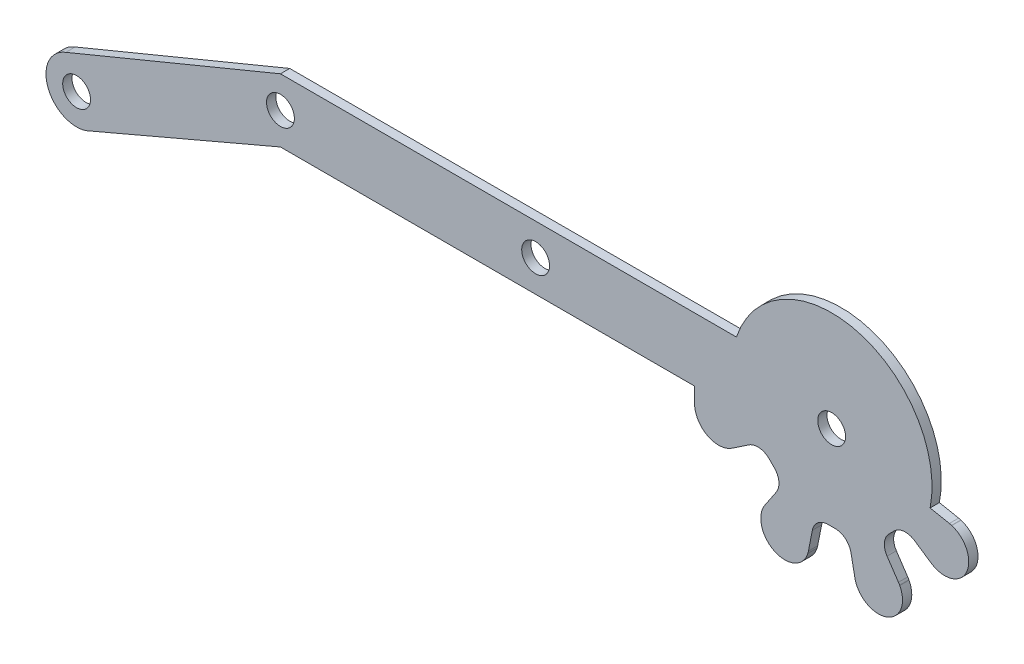
from build123d import *

# Parameters (mm, degrees)
MODEL_R                 = 1.5
SALIENTE_EXTRUIR1_DEPTH = 1


with BuildPart() as part:
    # Model → Saliente-Extruir1 (new body)
    with BuildSketch(Plane.XY):
        with BuildLine():
            Line((6.261217919, 18.769360839), (-14.739513879, 9.794996238))
            ThreePointArc((-14.739513879, 9.794996238), (-18.828558612, 11.883464999), (-16.872209477, 16.037341099))
            Line((-16.872209477, 16.037341099), (6.261217919, 25.600360839))
            Line((6.261217919, 25.600360839), (33.761217919, 25.600360839))
            Line((33.761217919, 25.600360839), (55.398917602, 25.600360839))
            ThreePointArc((55.398917602, 25.600360839), (68.422679159, 32.642144419), (76.271846628, 20.088433767))
            Line((76.271846628, 20.088433767), (78.346726924, 19.678483017))
            ThreePointArc((78.346726924, 19.678483017), (78.464143806, 19.652436824), (78.580224549, 19.620966371))
            Line((78.580224549, 19.620966371), (78.611928195, 19.611354587))
            ThreePointArc((78.611928195, 19.611354587), (80.237076178, 16.147342665), (76.638496698, 14.847069503))
            Line((76.638496698, 14.847069503), (76.609282278, 14.862690809))
            ThreePointArc((76.609282278, 14.862690809), (76.504947826, 14.922519319), (76.403504113, 14.987128153))
            Line((76.403504113, 14.987128153), (74.575103444, 16.212224841))
            ThreePointArc((74.575103444, 16.212224841), (73.415610314, 16.492916463), (72.35097411, 15.954621135))
            Line((72.35097411, 15.954621135), (71.891457622, 15.495104647))
            ThreePointArc((71.891457622, 15.495104647), (71.353162294, 14.430468442), (71.633853917, 13.270975311))
            Line((71.633853917, 13.270975311), (72.858950606, 11.442574643))
            ThreePointArc((72.858950606, 11.442574643), (72.92355944, 11.34113093), (72.98338795, 11.236796479))
            Line((72.98338795, 11.236796479), (72.999009256, 11.207582059))
            ThreePointArc((72.999009256, 11.207582059), (71.698736047, 7.609002556), (68.234724141, 9.234150662))
            Line((68.234724141, 9.234150662), (68.225112387, 9.265854208))
            ThreePointArc((68.225112387, 9.265854208), (68.193641935, 9.381934951), (68.167595742, 9.499351833))
            Line((68.167595742, 9.499351833), (67.740995408, 11.65850052))
            ThreePointArc((67.740995408, 11.65850052), (67.119588901, 12.676864925), (65.986145145, 13.049044127))
            Line((65.986145145, 13.049044127), (65.336290696, 13.049044127))
            ThreePointArc((65.336290696, 13.049044127), (64.20284694, 12.676864925), (63.581440434, 11.658500522))
            Line((63.581440434, 11.658500522), (63.154840098, 9.499351834))
            ThreePointArc((63.154840098, 9.499351834), (63.128793905, 9.381934952), (63.097323452, 9.265854209))
            Line((63.097323452, 9.265854209), (63.087711668, 9.234150563))
            ThreePointArc((63.087711668, 9.234150563), (59.623699794, 7.609002564), (58.323426536, 11.20758197))
            Line((58.323426536, 11.20758197), (58.33904789, 11.23679648))
            ThreePointArc((58.33904789, 11.23679648), (58.3988764, 11.341130932), (58.463485233, 11.442574645))
            Line((58.463485233, 11.442574645), (59.688581925, 13.270975312))
            ThreePointArc((59.688581925, 13.270975312), (59.969273546, 14.430468443), (59.430978219, 15.495104647))
            Line((59.430978219, 15.495104647), (58.971461731, 15.954621135))
            ThreePointArc((58.971461731, 15.954621135), (57.906825526, 16.492916463), (56.747332395, 16.21222484))
            Line((56.747332395, 16.21222484), (54.918931727, 14.987128151))
            ThreePointArc((54.918931727, 14.987128151), (54.817488014, 14.922519317), (54.713153563, 14.862690807))
            Line((54.713153563, 14.862690807), (54.683939143, 14.847069501))
            ThreePointArc((54.683939143, 14.847069501), (52.139490235, 14.921450429), (50.888257342, 17.138242934))
            Line((50.888257342, 17.138242934), (50.888257342, 18.769360839))
            Line((50.888257342, 18.769360839), (6.261217919, 18.769360839))
        make_face()
        with Locations((65.661217919, 22.184860839)):
            Circle(MODEL_R, mode=Mode.SUBTRACT)
        with Locations((33.761217919, 22.184860839)):
            Circle(MODEL_R, mode=Mode.SUBTRACT)
        with Locations((6.261217919, 22.184860839)):
            Circle(MODEL_R, mode=Mode.SUBTRACT)
        with Locations((-15.705782081, 12.950360839)):
            Circle(MODEL_R, mode=Mode.SUBTRACT)
    extrude(amount=SALIENTE_EXTRUIR1_DEPTH)


solid = part.part
